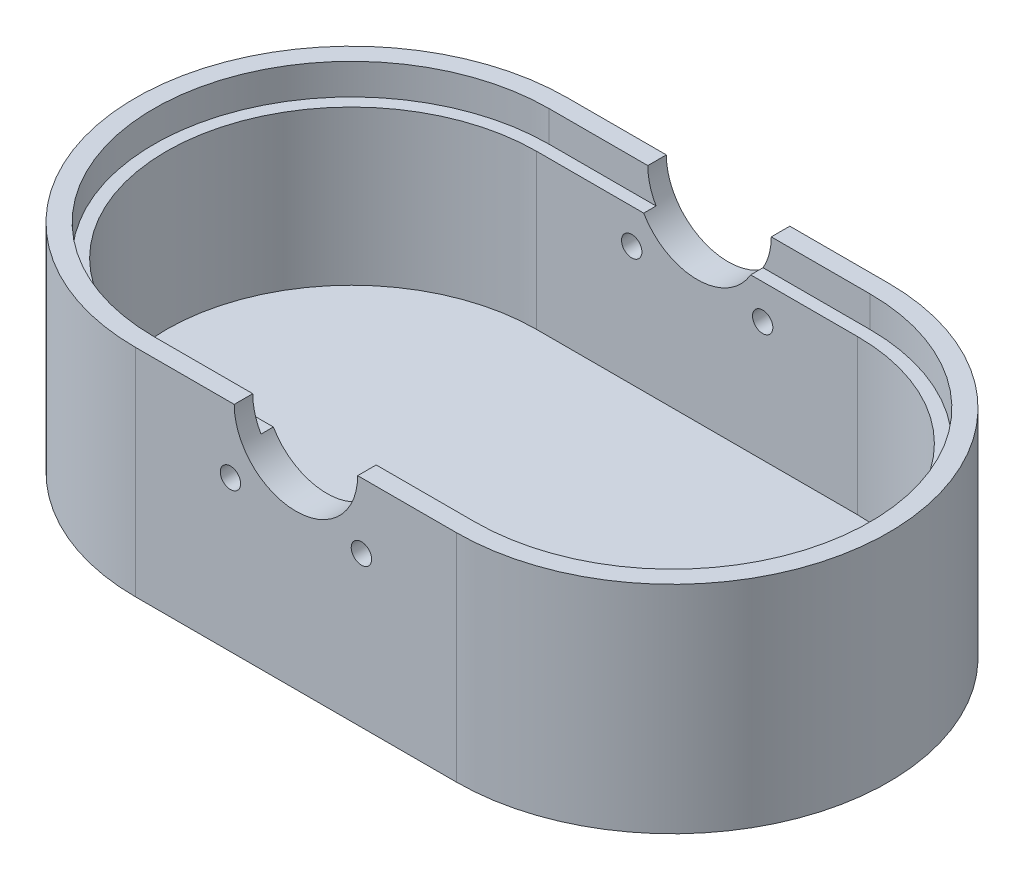
from build123d import *

# Parameters (mm, degrees)
EXTRUDE_1_DEPTH          = 35
CUT_EXTRUDE_1_DEPTH      = 30
SKETCH_3_R               = 10
CUT_EXTRUDE_2_DEPTH      = 1
CUT_EXTRUDE_2_DEPTH_BACK = 71
CUT_EXTRUDE_3_DEPTH      = 5
HOLE_WIZARD_M4_1_D       = 3.3
HOLE_WIZARD_M4_1_DEPTH   = 5
HOLE_WIZARD_M4_2_D       = 3.3
HOLE_WIZARD_M4_2_DEPTH   = 5


with BuildPart() as part:
    # 스케치1 → 보스-돌출1 (new body)
    with BuildSketch(Plane(origin=(0, 0, 0), x_dir=(1, 0, 0), z_dir=(0, 1, 0))):
        with BuildLine():
            Line((-26, 35), (26, 35))
            ThreePointArc((26, 35), (61, 0), (26, -35))
            Line((26, -35), (-26, -35))
            ThreePointArc((-26, -35), (-61, 0), (-26, 35))
        make_face()
    extrude(amount=EXTRUDE_1_DEPTH)

    # 스케치2 → 컷-돌출1 (cut)
    with BuildSketch(Plane(origin=(0, 35, 0), x_dir=(1, 0, 0), z_dir=(0, 1, 0))):
        with BuildLine():
            Line((26, 30), (-26, 30))
            ThreePointArc((-26, 30), (-56, 0), (-26, -30))
            Line((-26, -30), (26, -30))
            ThreePointArc((26, -30), (56, 0), (26, 30))
        make_face()
    extrude(amount=-CUT_EXTRUDE_1_DEPTH, mode=Mode.SUBTRACT)

    # 스케치3 → 컷-돌출2 (cut, two sides)
    with BuildSketch(Plane.XY.offset(35)) as cut_extrude_2_sk:
        with Locations((0, 35)):
            Circle(SKETCH_3_R)
    extrude(amount=CUT_EXTRUDE_2_DEPTH, mode=Mode.SUBTRACT)
    extrude(cut_extrude_2_sk.sketch, amount=-CUT_EXTRUDE_2_DEPTH_BACK, mode=Mode.SUBTRACT)

    # 스케치4 → 컷-돌출3 (cut)
    with BuildSketch(Plane(origin=(0, 35, 0), x_dir=(1, 0, 0), z_dir=(0, 1, 0))):
        with BuildLine():
            Line((-26, -32), (26, -32))
            ThreePointArc((26, -32), (58, 0), (26, 32))
            Line((26, 32), (-26, 32))
            ThreePointArc((-26, 32), (-58, 0), (-26, -32))
        make_face()
        with BuildLine():
            Line((-26, -30), (26, -30))
            ThreePointArc((26, -30), (56, 0), (26, 30))
            Line((26, 30), (-26, 30))
            ThreePointArc((-26, 30), (-56, 0), (-26, -30))
        make_face(mode=Mode.SUBTRACT)
    extrude(amount=-CUT_EXTRUDE_3_DEPTH, mode=Mode.SUBTRACT)

    # M4 나사 구멍1
    with Locations(Plane.XY.offset(35)):
        with Locations((-10.606601718, 24.393398282), (10.606601718, 24.393398282)):
            Hole(HOLE_WIZARD_M4_1_D / 2, depth=HOLE_WIZARD_M4_1_DEPTH)

    # M4 나사 구멍2
    with Locations(Plane(origin=(0, 0, -35), x_dir=(-1, 0, 0), z_dir=(0, 0, -1))):
        with Locations((-10.606601718, 24.393398282), (10.606601718, 24.393398282)):
            Hole(HOLE_WIZARD_M4_2_D / 2, depth=HOLE_WIZARD_M4_2_DEPTH)


solid = part.part
